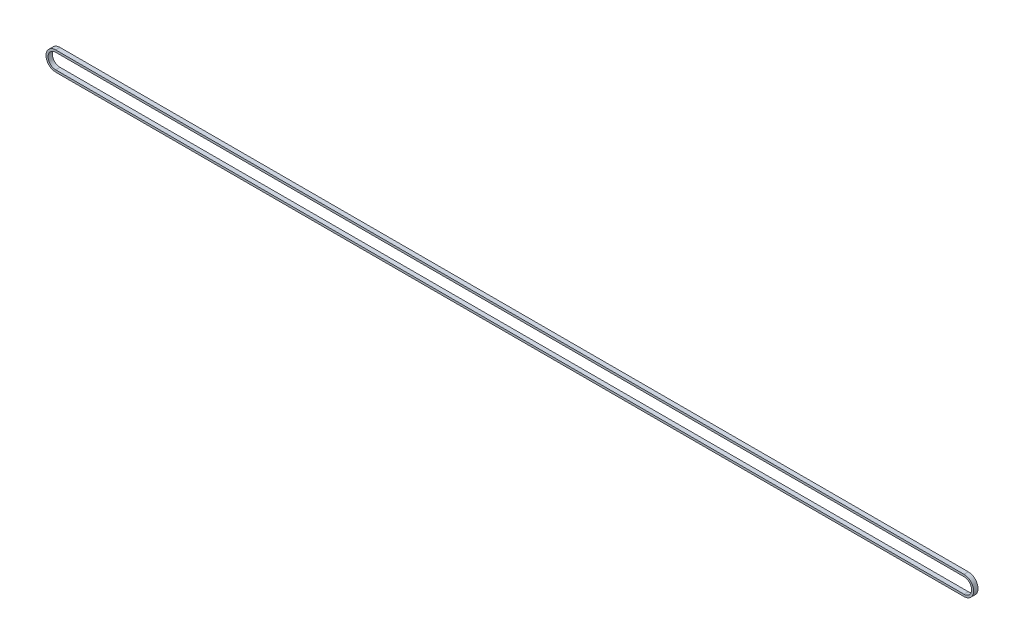
from build123d import *

# Parameters (mm, degrees)
EXTRUDE_THIN1_DEPTH = 2.5


with BuildPart() as part:
    # Sketch1 → Extrude-Thin1 (new body, symmetric)
    with BuildSketch(Plane.XY):
        with BuildLine():
            Line((1047.8, -11.15), (0, -11.15))
            ThreePointArc((0, -11.15), (-11.15, 0), (0, 11.15))
            Line((0, 11.15), (1047.8, 11.15))
            ThreePointArc((1047.8, 11.15), (1058.95, 0), (1047.8, -11.15))
        make_face()
        with BuildLine():
            Line((1047.8, -8.75), (0, -8.75))
            ThreePointArc((0, -8.75), (-8.75, 0), (0, 8.75))
            Line((0, 8.75), (1047.8, 8.75))
            ThreePointArc((1047.8, 8.75), (1056.55, 0), (1047.8, -8.75))
        make_face(mode=Mode.SUBTRACT)
    extrude(amount=EXTRUDE_THIN1_DEPTH, both=True)


solid = part.part
